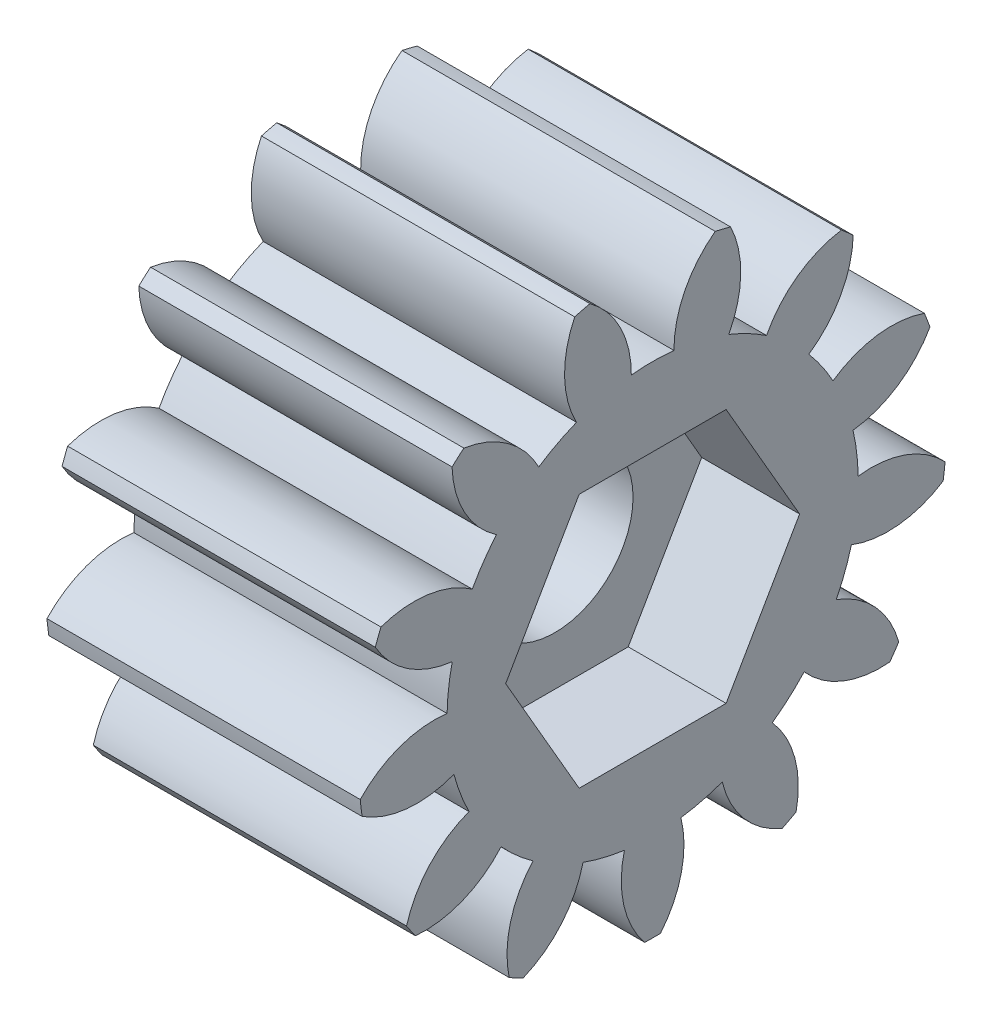
from build123d import *

# Parameters (mm, degrees)
BASPROSKE_W        = 16
BASPROSKE_H        = 15
TOOTHCUT_DEPTH     = 27.570660511
TEETHCUTS_COUNT    = 13
TEETHCUTS_ANGLE    = 332.307692308
BORSKE_R           = 4
BORE_DEPTH         = 50.0000508
CUT_EXTRUDE1_DEPTH = 5


with BuildPart() as part:
    # BasProSke → Base-Revolve (revolve)
    with BuildSketch(Plane(origin=(0, 0, 0), x_dir=(1, 0, 0), z_dir=(0, 1, 0)), mode=Mode.PRIVATE) as base_revolve_sk:
        with Locations((8, 7.5)):
            Rectangle(BASPROSKE_W, BASPROSKE_H)
    revolve(base_revolve_sk.sketch.rotate(Axis((-10, 0, 0), (1, 0, 0)), 180), axis=Axis((-10, 0, 0), (1, 0, 0)))

    # TooCutSke → ToothCut (cut, through all)
    with BuildSketch(Plane(origin=(0, 0, 0), x_dir=(0, 0, -1), z_dir=(1, 0, 0))):
        with BuildLine():
            ThreePointArc((1.088245291, 10.442448141), (0, 10.499), (-1.088245291, 10.442448141))
            ThreePointArc((-1.088245291, 10.442448141), (-1.646045958, 12.816546547), (-3.224884568, 14.675243258))
            ThreePointArc((-3.224884568, 14.675243258), (0, 15.0254), (3.224884568, 14.675243258))
            ThreePointArc((3.224884568, 14.675243258), (1.646045958, 12.816546547), (1.088245291, 10.442448141))
        make_face()
    toothcut = extrude(amount=TOOTHCUT_DEPTH, mode=Mode.SUBTRACT)

    # TeethCuts: ToothCut ×13 about axis
    teethcuts_axis = Axis((-10, 0, 0), (1, 0, 0))
    for i in range(1, TEETHCUTS_COUNT):
        add(toothcut.rotate(teethcuts_axis, i * TEETHCUTS_ANGLE / (TEETHCUTS_COUNT - 1)), mode=Mode.SUBTRACT)

    # BorSke → Bore (cut, symmetric)
    with BuildSketch(Plane(origin=(0, 0, 0), x_dir=(0, 0, -1), z_dir=(1, 0, 0))):
        with Locations(Location((0, 0, 0), (0, 0, 180))):
            Circle(BORSKE_R)
    extrude(amount=BORE_DEPTH, both=True, mode=Mode.SUBTRACT)

    # Sketch1 → Cut-Extrude1 (cut)
    with BuildSketch(Plane(origin=(16, 0, 0), x_dir=(0, 0, -1), z_dir=(1, 0, 0))):
        Polygon((-3.75277675, 6.5), (-7.505553499, 0), (-3.75277675, -6.5), (3.75277675, -6.5), (7.505553499, 0), (3.75277675, 6.5), align=None)
    extrude(amount=-CUT_EXTRUDE1_DEPTH, mode=Mode.SUBTRACT)


solid = part.part
